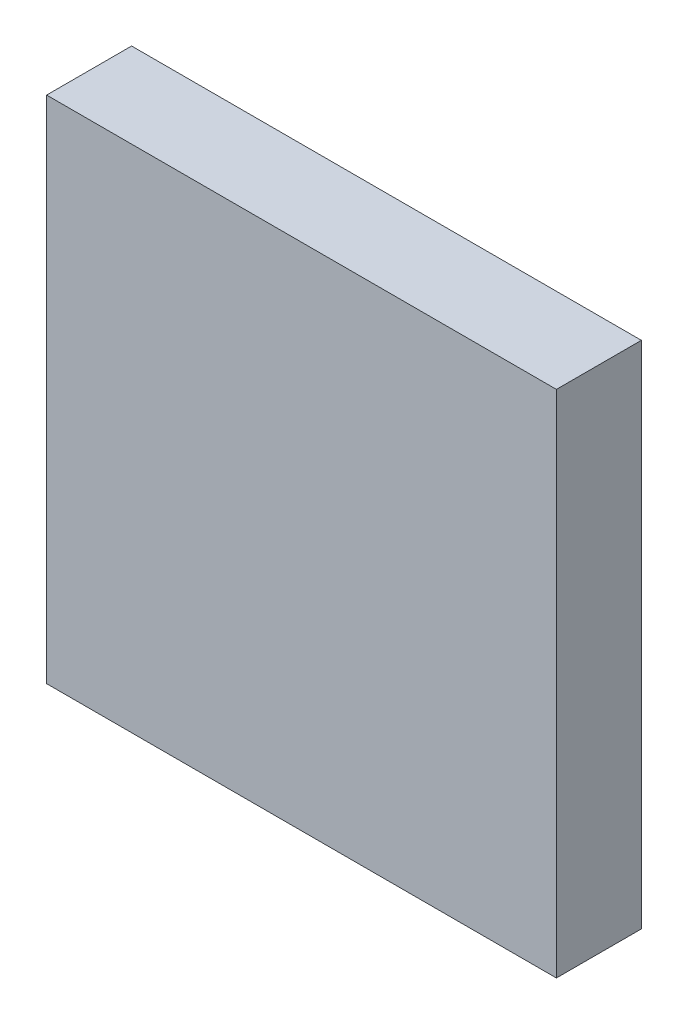
from build123d import *

# Parameters (mm, degrees)
SCHIZZO1_W                   = 60
SCHIZZO1_H                   = 60
ESTRUSIONE_ESTRUSIONE1_DEPTH = 10


with BuildPart() as part:
    # Schizzo1 → Estrusione-Estrusione1 (new body)
    with BuildSketch(Plane.XY):
        Rectangle(SCHIZZO1_W, SCHIZZO1_H)
    extrude(amount=ESTRUSIONE_ESTRUSIONE1_DEPTH)


solid = part.part
